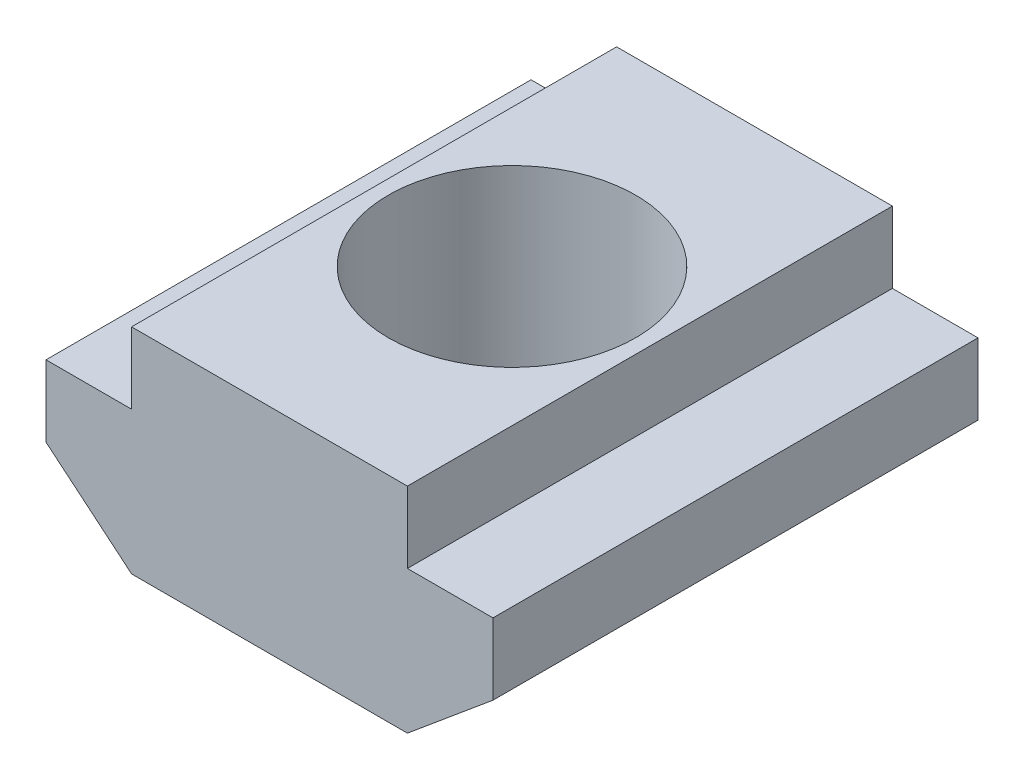
from build123d import *

# Parameters (mm, degrees)
EXTRUDE_1_DEPTH   = 10.2
HOLE_WIZARD_M51_D = 5.2


with BuildPart() as part:
    # Эскиз1 → Бобышка-Вытянуть1 (new body)
    with BuildSketch(Plane.XY):
        Polygon((0, 3), (0, 1.5), (1.8, 0), (7.6, 0), (9.4, 1.5), (9.4, 3), (7.6, 3), (7.6, 4.5), (1.8, 4.5), (1.8, 3), align=None)
    extrude(amount=EXTRUDE_1_DEPTH)

    # Сверло под метчик  спиральное M51 (through all)
    with Locations(Plane(origin=(0, 4.5, 0), x_dir=(1, 0, 0), z_dir=(0, 1, 0))):
        with Locations((4.7, -5.1)):
            Hole(HOLE_WIZARD_M51_D / 2)


solid = part.part
